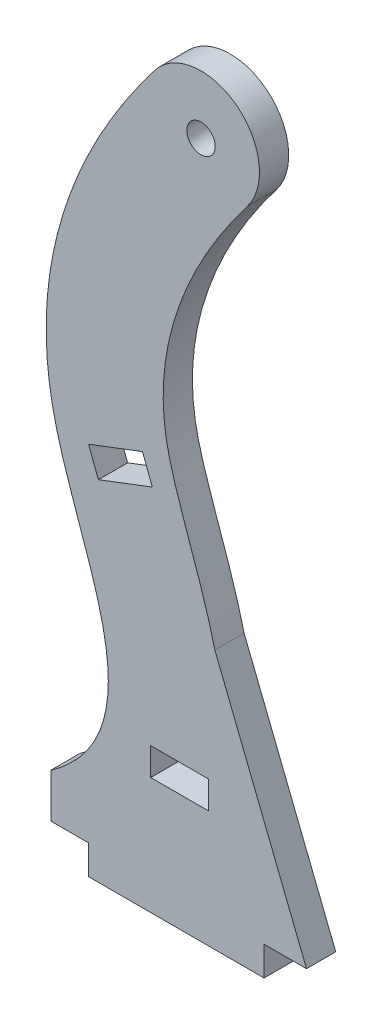
from build123d import *

# Parameters (mm, degrees)
SKETCH1_R           = 3.0861
SKETCH1_W           = 12.5222
SKETCH1_H           = 5.9944
BOSS_EXTRUDE1_DEPTH = 6.35


with BuildPart() as part:
    # Sketch1 → Boss-Extrude1 (new body)
    with BuildSketch(Plane.XY):
        with BuildLine():
            Line((0, 0), (8.17063217, 0))
            Line((8.17063217, 0), (8.17063217, -6.35))
            Line((8.17063217, -6.35), (46.27063217, -6.35))
            Line((46.27063217, -6.35), (46.27063217, 0))
            Line((46.27063217, 0), (55.488574343, 0))
            Line((55.488574343, 0), (35.593928158, 49.97151257))
            add(Edge.make_bspline(
                [(35.593928158, 49.97151257), (35.340737153, 51.011091182), (34.289692424, 55.03884072), (31.957417171, 62.348344314), (29.449052089, 69.339178116), (27.57881277, 74.801296199), (26.423935243, 78.479850782), (25.55485091, 81.728738299), (24.788233703, 85.483659955), (24.284352637, 90.308612383), (24.428183006, 96.20335615), (25.327585112, 102.354497696), (27.029689584, 108.787993917), (29.577624998, 115.505437797), (32.431224266, 121.309144006), (35.158066015, 126.048842881), (37.424080544, 129.643418636), (39.497556945, 132.668231109), (41.261681964, 135.095684908), (42.186501173, 136.321547482), (42.651516027, 136.926910036)],
                knots=[0.250437186, 0.250437186, 0.250437186, 0.250437186, 0.266062186, 0.3125, 0.375, 0.40625, 0.4375, 0.46875, 0.5, 0.5625, 0.625, 0.6875, 0.75, 0.8125, 0.875, 0.90625, 0.9375, 0.96875, 0.984375, 1, 1, 1, 1], degree=3))
            ThreePointArc((42.651516027, 136.926910036), (40.316523303, 154.734992723), (22.508440616, 152.4))
            add(Edge.make_bspline(
                [(0, 9.589675689), (16.950704725, 21.543735705), (11.362052202, 46.597336486), (-7.636318626, 94.064001484), (3.941433469, 128.229221831), (22.508440616, 152.4)],
                knots=[0, 0, 0, 0, 0.312818519, 0.480279904, 1, 1, 1, 1], degree=3))
            Line((0, 9.589675689), (0, 0))
        make_face()
        with Locations((32.579978321, 144.663455018)):
            Circle(SKETCH1_R, mode=Mode.SUBTRACT)
        Polygon((8.17063217, 74.955854978), (10.310412852, 69.356375539), (22.007630495, 73.826341117), (19.867849812, 79.425820556), align=None, mode=Mode.SUBTRACT)
        with Locations((27.92484424, 22.035916142)):
            Rectangle(SKETCH1_W, SKETCH1_H, mode=Mode.SUBTRACT)
    extrude(amount=BOSS_EXTRUDE1_DEPTH)


solid = part.part
